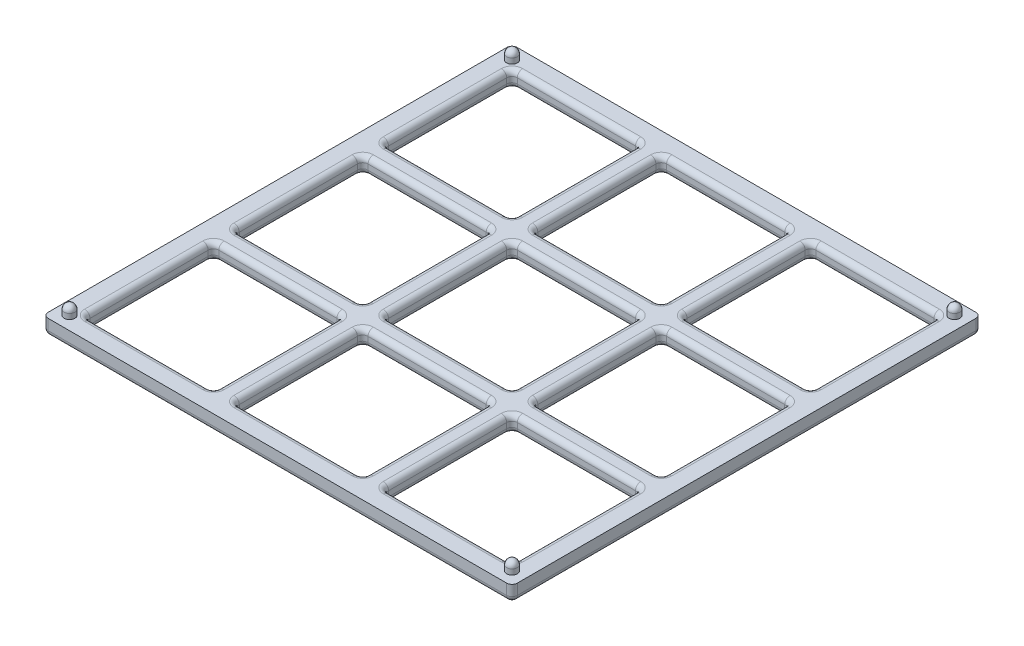
from build123d import *

# Parameters (mm, degrees)
SKETCH1_W           = 139.7
SKETCH1_H           = 139.7
BOSS_EXTRUDE1_DEPTH = 4.7625
SKETCH2_W           = 38.354
SKETCH2_H           = 38.354
CUT_EXTRUDE1_DEPTH  = 4.7625
FILLET2_R           = 1.5875
SKETCH3_R           = 1.5875
BOSS_EXTRUDE2_DEPTH = 3.175
FILLET3_R           = 1.5875


with BuildPart() as part:
    # Sketch1 → Boss-Extrude1 (new body)
    with BuildSketch(Plane(origin=(0, 0, 0), x_dir=(1, 0, 0), z_dir=(0, 1, 0))):
        Rectangle(SKETCH1_W, SKETCH1_H)
    extrude(amount=BOSS_EXTRUDE1_DEPTH)

    # Sketch2 → Cut-Extrude1 (cut)
    with BuildSketch(Plane(origin=(0, 4.7625, 0), x_dir=(1, 0, 0), z_dir=(0, 1, 0))):
        with Locations((-44.45, 44.45)):
            Rectangle(SKETCH2_W, SKETCH2_H)
        with Locations((0, 44.45)):
            Rectangle(SKETCH2_W, SKETCH2_H)
        with Locations((44.45, 44.45)):
            Rectangle(SKETCH2_W, SKETCH2_H)
        Rectangle(SKETCH2_W, SKETCH2_H)
        with Locations((44.45, 0)):
            Rectangle(SKETCH2_W, SKETCH2_H)
        with Locations((0, -44.45)):
            Rectangle(SKETCH2_W, SKETCH2_H)
        with Locations((44.45, -44.45)):
            Rectangle(SKETCH2_W, SKETCH2_H)
        with Locations((-44.45, 0)):
            Rectangle(SKETCH2_W, SKETCH2_H)
        with Locations((-44.45, -44.45)):
            Rectangle(SKETCH2_W, SKETCH2_H)
    extrude(amount=-CUT_EXTRUDE1_DEPTH, mode=Mode.SUBTRACT)

    # Fillet2
    fillet2_edges = [part.edges().sort_by_distance(p)[0] for p in [
        (-25.273, 0, 0),
        (-25.273, 2.38125, -19.177),
        (-44.45, 0, 19.177),
        (-25.273, 2.38125, 19.177),
        (-63.627, 0, 0),
        (-63.627, 2.38125, 19.177),
        (-44.45, 0, -19.177),
        (-63.627, 2.38125, -19.177),
        (-25.273, 4.7625, 0),
        (-44.45, 4.7625, -19.177),
        (-63.627, 4.7625, 0),
        (-44.45, 4.7625, 19.177),
        (-25.273, 0, 44.45),
        (-25.273, 2.38125, 25.273),
        (-44.45, 0, 63.627),
        (-25.273, 2.38125, 63.627),
        (-63.627, 0, 44.45),
        (-63.627, 2.38125, 63.627),
        (-44.45, 0, 25.273),
        (-63.627, 2.38125, 25.273),
        (-25.273, 4.7625, 44.45),
        (-44.45, 4.7625, 25.273),
        (-63.627, 4.7625, 44.45),
        (-44.45, 4.7625, 63.627),
        (-25.273, 0, -44.45),
        (-25.273, 2.38125, -63.627),
        (-44.45, 0, -25.273),
        (-25.273, 2.38125, -25.273),
        (-63.627, 0, -44.45),
        (-63.627, 2.38125, -25.273),
        (-44.45, 0, -63.627),
        (-63.627, 2.38125, -63.627),
        (-25.273, 4.7625, -44.45),
        (-44.45, 4.7625, -63.627),
        (-63.627, 4.7625, -44.45),
        (-44.45, 4.7625, -25.273),
        (19.177, 0, -44.45),
        (19.177, 2.38125, -63.627),
        (0, 0, -25.273),
        (19.177, 2.38125, -25.273),
        (-19.177, 0, -44.45),
        (-19.177, 2.38125, -25.273),
        (0, 0, -63.627),
        (-19.177, 2.38125, -63.627),
        (19.177, 4.7625, -44.45),
        (0, 4.7625, -63.627),
        (-19.177, 4.7625, -44.45),
        (0, 4.7625, -25.273),
        (63.627, 0, -44.45),
        (63.627, 2.38125, -63.627),
        (44.45, 0, -25.273),
        (63.627, 2.38125, -25.273),
        (25.273, 0, -44.45),
        (25.273, 2.38125, -25.273),
        (44.45, 0, -63.627),
        (25.273, 2.38125, -63.627),
        (63.627, 4.7625, -44.45),
        (0, 0, 69.85),
        (44.45, 4.7625, -63.627),
        (25.273, 4.7625, -44.45),
        (44.45, 4.7625, -25.273),
        (-69.85, 0, 0),
        (0, 0, -69.85),
        (19.177, 0, 0),
        (19.177, 2.38125, -19.177),
        (0, 0, 19.177),
        (69.85, 0, 0),
        (19.177, 2.38125, 19.177),
        (-19.177, 0, 0),
        (-19.177, 2.38125, 19.177),
        (0, 0, -19.177),
        (-19.177, 2.38125, -19.177),
        (19.177, 4.7625, 0),
        (0, 4.7625, -19.177),
        (-19.177, 4.7625, 0),
        (0, 4.7625, 19.177),
        (63.627, 0, 0),
        (63.627, 2.38125, -19.177),
        (44.45, 0, 19.177),
        (63.627, 2.38125, 19.177),
        (25.273, 0, 0),
        (25.273, 2.38125, 19.177),
        (44.45, 0, -19.177),
        (25.273, 2.38125, -19.177),
        (63.627, 4.7625, 0),
        (44.45, 4.7625, -19.177),
        (25.273, 4.7625, 0),
        (44.45, 4.7625, 19.177),
        (69.85, 2.38125, 69.85),
        (-69.85, 2.38125, 69.85),
        (-69.85, 2.38125, -69.85),
        (69.85, 2.38125, -69.85),
        (19.177, 0, 44.45),
        (19.177, 2.38125, 25.273),
        (0, 0, 63.627),
        (19.177, 2.38125, 63.627),
        (-19.177, 0, 44.45),
        (-19.177, 2.38125, 63.627),
        (0, 0, 25.273),
        (-19.177, 2.38125, 25.273),
        (19.177, 4.7625, 44.45),
        (0, 4.7625, 25.273),
        (-19.177, 4.7625, 44.45),
        (0, 4.7625, 63.627),
        (63.627, 0, 44.45),
        (63.627, 2.38125, 25.273),
        (44.45, 0, 63.627),
        (63.627, 2.38125, 63.627),
        (25.273, 0, 44.45),
        (25.273, 2.38125, 63.627),
        (44.45, 0, 25.273),
        (25.273, 2.38125, 25.273),
        (63.627, 4.7625, 44.45),
        (44.45, 4.7625, 25.273),
        (25.273, 4.7625, 44.45),
        (44.45, 4.7625, 63.627),
    ]]
    fillet(fillet2_edges, radius=FILLET2_R)

    # Sketch3 → Boss-Extrude2 (add)
    with BuildSketch(Plane(origin=(0, 4.7625, 0), x_dir=(1, 0, 0), z_dir=(0, 1, 0))):
        with Locations((-65.88125, 65.88125)):
            Circle(SKETCH3_R)
        with Locations((65.88125, 65.88125)):
            Circle(SKETCH3_R)
        with Locations((65.88125, -65.88125)):
            Circle(SKETCH3_R)
        with Locations((-65.88125, -65.88125)):
            Circle(SKETCH3_R)
    extrude(amount=BOSS_EXTRUDE2_DEPTH)

    # Fillet3
    fillet3_edges = [part.edges().sort_by_distance(p)[0] for p in [
        (-67.46875, 7.9375, -65.88125),
        (64.29375, 7.9375, -65.88125),
        (64.29375, 7.9375, 65.88125),
        (-67.46875, 7.9375, 65.88125),
    ]]
    fillet(fillet3_edges, radius=FILLET3_R)


solid = part.part
